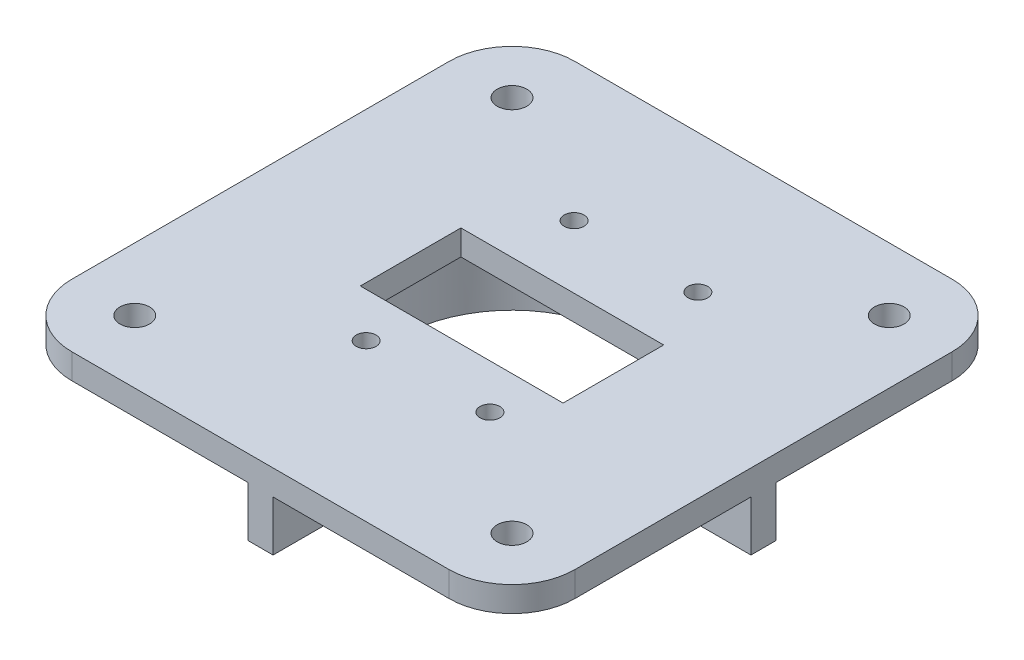
from build123d import *

# Parameters (mm, degrees)
SKETCH1_R           = 1.5
SKETCH1_R_2         = 11.43
BOSS_EXTRUDE1_DEPTH = 7.62
CUT_EXTRUDE1_DEPTH  = 5.08
BOSS_EXTRUDE2_DEPTH = 2.54
SKETCH4_R           = 1
CUT_EXTRUDE2_DEPTH  = 8.62


with BuildPart() as part:
    # Sketch1 → Boss-Extrude1 (new body)
    with BuildSketch(Plane(origin=(0, 0, 0), x_dir=(1, 0, 0), z_dir=(0, 1, 0))):
        with BuildLine():
            Line((6.35, 0), (44.45, 0))
            ThreePointArc((44.45, 0), (48.940128061, 1.859871939), (50.8, 6.35))
            Line((50.8, 6.35), (50.8, 44.45))
            ThreePointArc((50.8, 44.45), (48.940128061, 48.940128061), (44.45, 50.8))
            Line((44.45, 50.8), (6.35, 50.8))
            ThreePointArc((6.35, 50.8), (1.859871939, 48.940128061), (0, 44.45))
            Line((0, 44.45), (0, 6.35))
            ThreePointArc((0, 6.35), (1.859871939, 1.859871939), (6.35, 0))
        make_face()
        with Locations((6.35, 6.35)):
            Circle(SKETCH1_R, mode=Mode.SUBTRACT)
        with Locations((6.35, 44.45)):
            Circle(SKETCH1_R, mode=Mode.SUBTRACT)
        with Locations((44.45, 44.45)):
            Circle(SKETCH1_R, mode=Mode.SUBTRACT)
        with Locations((44.45, 6.35)):
            Circle(SKETCH1_R, mode=Mode.SUBTRACT)
        with Locations((25.4, 25.4)):
            Circle(SKETCH1_R_2, mode=Mode.SUBTRACT)
    extrude(amount=BOSS_EXTRUDE1_DEPTH)

    # Sketch2 → Cut-Extrude1 (cut)
    with BuildSketch(Plane.XZ):
        with BuildLine():
            Line((8.938918626, -26.67), (0, -26.67))
            Line((0, -26.67), (0, -50.8))
            Line((0, -50.8), (24.13, -50.8))
            Line((24.13, -50.8), (24.13, -41.861081374))
            ThreePointArc((24.13, -41.861081374), (13.725667043, -37.074332957), (8.938918626, -26.67))
        make_face()
        with BuildLine():
            Line((0, 0), (0, -24.13))
            Line((0, -24.13), (8.938918626, -24.13))
            ThreePointArc((8.938918626, -24.13), (13.725667043, -13.725667043), (24.13, -8.938918626))
            Line((24.13, -8.938918626), (24.13, 0))
            Line((24.13, 0), (0, 0))
        make_face()
        with BuildLine():
            ThreePointArc((41.861081374, -26.67), (37.074332957, -37.074332957), (26.67, -41.861081374))
            Line((26.67, -41.861081374), (26.67, -50.8))
            Line((26.67, -50.8), (50.8, -50.8))
            Line((50.8, -50.8), (50.8, -26.67))
            Line((50.8, -26.67), (41.861081374, -26.67))
        make_face()
        with BuildLine():
            Line((26.67, 0), (26.67, -8.938918626))
            ThreePointArc((26.67, -8.938918626), (37.074332957, -13.725667043), (41.861081374, -24.13))
            Line((41.861081374, -24.13), (50.8, -24.13))
            Line((50.8, -24.13), (50.8, 0))
            Line((50.8, 0), (26.67, 0))
        make_face()
    extrude(amount=-CUT_EXTRUDE1_DEPTH, mode=Mode.SUBTRACT)

    # Sketch3 → Boss-Extrude2 (add)
    with BuildSketch(Plane(origin=(0, 7.62, 0), x_dir=(1, 0, 0), z_dir=(0, 1, 0))):
        with BuildLine():
            Line((35.63906734, 20.32), (15.16093266, 20.32))
            ThreePointArc((15.16093266, 20.32), (25.4, 13.97), (35.63906734, 20.32))
        make_face()
        with BuildLine():
            ThreePointArc((15.16093266, 30.48), (13.97, 25.4), (15.16093266, 20.32))
            Line((15.16093266, 20.32), (15.16093266, 30.48))
        make_face()
        with BuildLine():
            ThreePointArc((35.63906734, 30.48), (25.4, 36.83), (15.16093266, 30.48))
            Line((15.16093266, 30.48), (35.63906734, 30.48))
        make_face()
        with BuildLine():
            Line((35.63906734, 30.48), (35.63906734, 20.32))
            ThreePointArc((35.63906734, 20.32), (36.528284677, 22.791134317), (36.83, 25.4))
            ThreePointArc((36.83, 25.4), (36.528284677, 28.008865683), (35.63906734, 30.48))
        make_face()
    extrude(amount=-BOSS_EXTRUDE2_DEPTH)

    # Sketch4 → Cut-Extrude2 (cut, through all)
    with BuildSketch(Plane(origin=(0, 7.62, 0), x_dir=(1, 0, 0), z_dir=(0, 1, 0))):
        with Locations((20.24093266, 36.83)):
            Circle(SKETCH4_R)
        with Locations((32.74093266, 36.83)):
            Circle(SKETCH4_R)
        with Locations((20.24093266, 15.83)):
            Circle(SKETCH4_R)
        with Locations((32.74093266, 15.83)):
            Circle(SKETCH4_R)
    extrude(amount=-CUT_EXTRUDE2_DEPTH, mode=Mode.SUBTRACT)


solid = part.part
